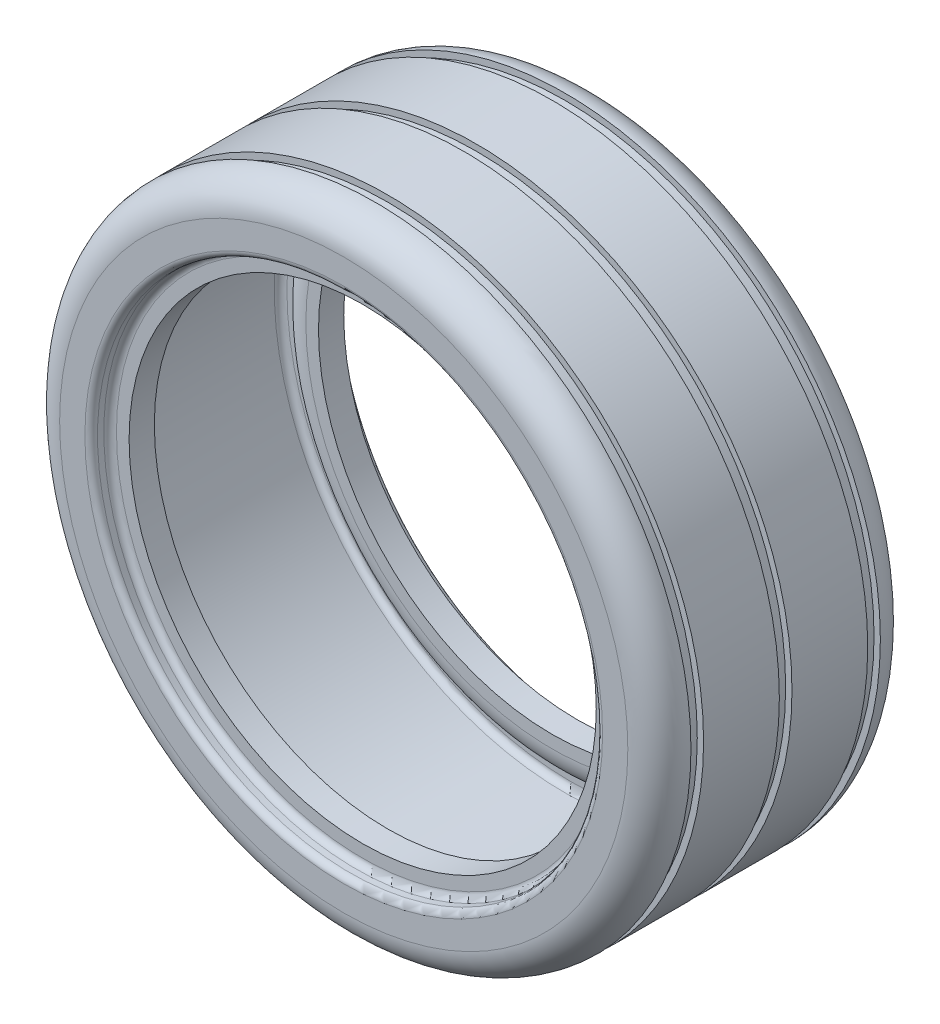
from build123d import *

# Parameters (mm, degrees)
SKETCH2_W    = 4
SKETCH2_H    = 26.364045801
SCALE1_SCALE = 0.5


with BuildPart() as part:
    # Sketch1 → Revolve1 (revolve)
    with BuildSketch(Plane(origin=(0, 0, 0), x_dir=(0, 0, -1), z_dir=(1, 0, 0)), mode=Mode.PRIVATE) as revolve1_sk:
        with BuildLine():
            Line((0, 180), (30, 180))
            ThreePointArc((30, 180), (37.071067812, 177.071067812), (40, 170))
            Line((40, 170), (40, 162))
            ThreePointArc((40, 162), (39.414213562, 160.585786438), (38, 160))
            Line((38, 160), (36, 160))
            ThreePointArc((36, 160), (34.585786438, 159.414213562), (34, 158))
            Line((34, 158), (34, 154))
            Line((34, 154), (26, 154))
            Line((26, 154), (26, 158))
            ThreePointArc((26, 158), (27.633399735, 163.477225575), (32, 167.16515139))
            Line((32, 167.16515139), (32, 170))
            ThreePointArc((32, 170), (31.414213562, 171.414213562), (30, 172))
            Line((30, 172), (0, 172))
            Line((0, 172), (-30, 172))
            ThreePointArc((-30, 172), (-31.414213562, 171.414213562), (-32, 170))
            Line((-32, 170), (-32, 167.16515139))
            ThreePointArc((-32, 167.16515139), (-27.633399735, 163.477225575), (-26, 158))
            Line((-26, 158), (-26, 154))
            Line((-26, 154), (-34, 154))
            Line((-34, 154), (-34, 158))
            ThreePointArc((-34, 158), (-34.585786438, 159.414213562), (-36, 160))
            Line((-36, 160), (-38, 160))
            ThreePointArc((-38, 160), (-39.414213562, 160.585786438), (-40, 162))
            Line((-40, 162), (-40, 170))
            ThreePointArc((-40, 170), (-37.071067812, 177.071067812), (-30, 180))
            Line((-30, 180), (0, 180))
        make_face()
    revolve(revolve1_sk.sketch.rotate(Axis((0, 80, 0), (0, 0, -1)), 90), axis=Axis((0, 80, 0), (0, 0, -1)))

    # Sketch2 → Cut-Revolve1 (revolve, cut)
    with BuildSketch(Plane(origin=(0, 0, 0), x_dir=(0, 0, -1), z_dir=(1, 0, 0)), mode=Mode.PRIVATE) as cut_revolve1_sk:
        with Locations((28, 191.1820229)):
            Rectangle(SKETCH2_W, SKETCH2_H)
        with Locations((-28, 191.1820229)):
            Rectangle(SKETCH2_W, SKETCH2_H)
        with Locations((0, 191.1820229)):
            Rectangle(SKETCH2_W, SKETCH2_H)
    revolve(cut_revolve1_sk.sketch.rotate(Axis((0, 80, -30), (0, 0, 1)), 90), axis=Axis((0, 80, -30), (0, 0, 1)), mode=Mode.SUBTRACT)


with BuildPart() as part_1:
    # Scale1: scaled about (0, 80, 0)
    add(part.part.scale(SCALE1_SCALE).moved(Location((0, 40, 0))))


solid = part_1.part
